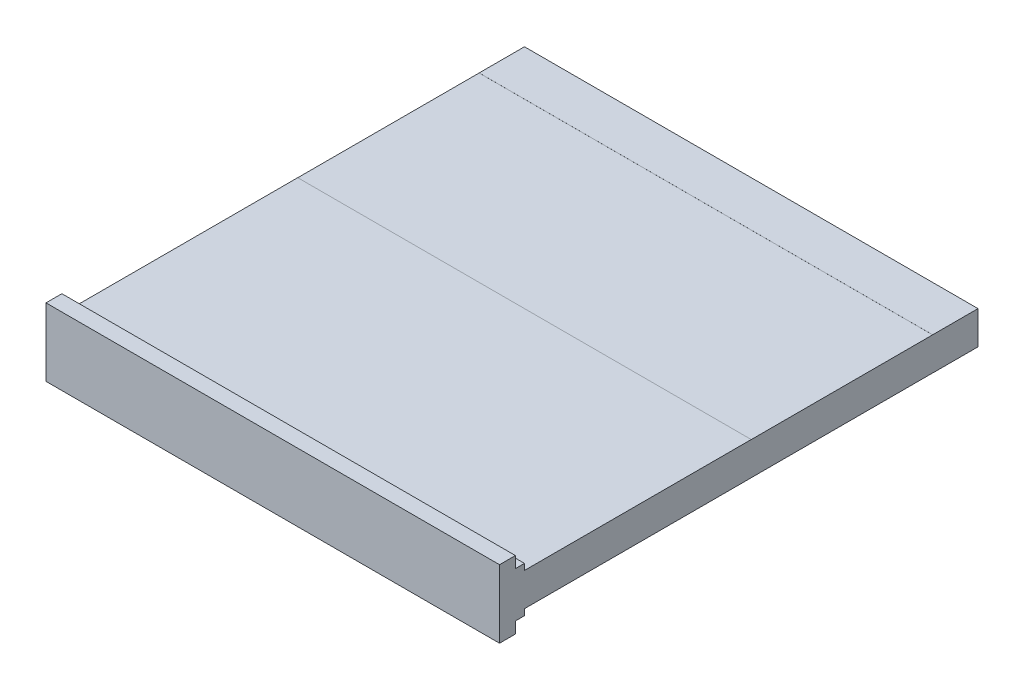
from build123d import *

# Parameters (mm, degrees)
SKETCH1_W           = 1
SKETCH1_H           = 0.072865
BOSS_EXTRUDE1_DEPTH = 1
SKETCH2_W           = 1
SKETCH2_H           = 0.1
BOSS_EXTRUDE2_DEPTH = 0.02
SKETCH3_W           = 1
SKETCH3_H           = 0.15
BOSS_EXTRUDE3_DEPTH = 0.035
SKETCH4_W           = 1
SKETCH4_H           = 0.1
SKETCH4_H_2         = 0.5
BOSS_EXTRUDE4_DEPTH = 0.0001
SKETCH6_W           = 1
SKETCH6_H           = 0.1
SKETCH6_H_2         = 0.5
BOSS_EXTRUDE5_DEPTH = 0.0001


with BuildPart() as part:
    # Sketch1 → Boss-Extrude1 (new body)
    with BuildSketch(Plane.XY):
        with Locations((0.5, 0.0364325)):
            Rectangle(SKETCH1_W, SKETCH1_H)
    extrude(amount=BOSS_EXTRUDE1_DEPTH)

    # Sketch2 → Boss-Extrude2 (add)
    with BuildSketch(Plane.XY.offset(1)):
        with Locations((0.5, 0.0364325)):
            Rectangle(SKETCH2_W, SKETCH2_H)
    extrude(amount=BOSS_EXTRUDE2_DEPTH)

    # Sketch3 → Boss-Extrude3 (add)
    with BuildSketch(Plane.XY.offset(1.02)):
        with Locations((0.5, 0.0364325)):
            Rectangle(SKETCH3_W, SKETCH3_H)
    extrude(amount=BOSS_EXTRUDE3_DEPTH)

    # Sketch4 → Boss-Extrude4 (add)
    with BuildSketch(Plane.XZ):
        with Locations((0.5, 0.05)):
            Rectangle(SKETCH4_W, SKETCH4_H)
        with Locations((0.5, 0.75)):
            Rectangle(SKETCH4_W, SKETCH4_H_2)
    extrude(amount=BOSS_EXTRUDE4_DEPTH)

    # Sketch6 → Boss-Extrude5 (add)
    with BuildSketch(Plane(origin=(0, 0.072865, 0), x_dir=(1, 0, 0), z_dir=(0, 1, 0))):
        with Locations((0.5, -0.05)):
            Rectangle(SKETCH6_W, SKETCH6_H)
        with Locations((0.5, -0.75)):
            Rectangle(SKETCH6_W, SKETCH6_H_2)
    extrude(amount=BOSS_EXTRUDE5_DEPTH)


solid = part.part
